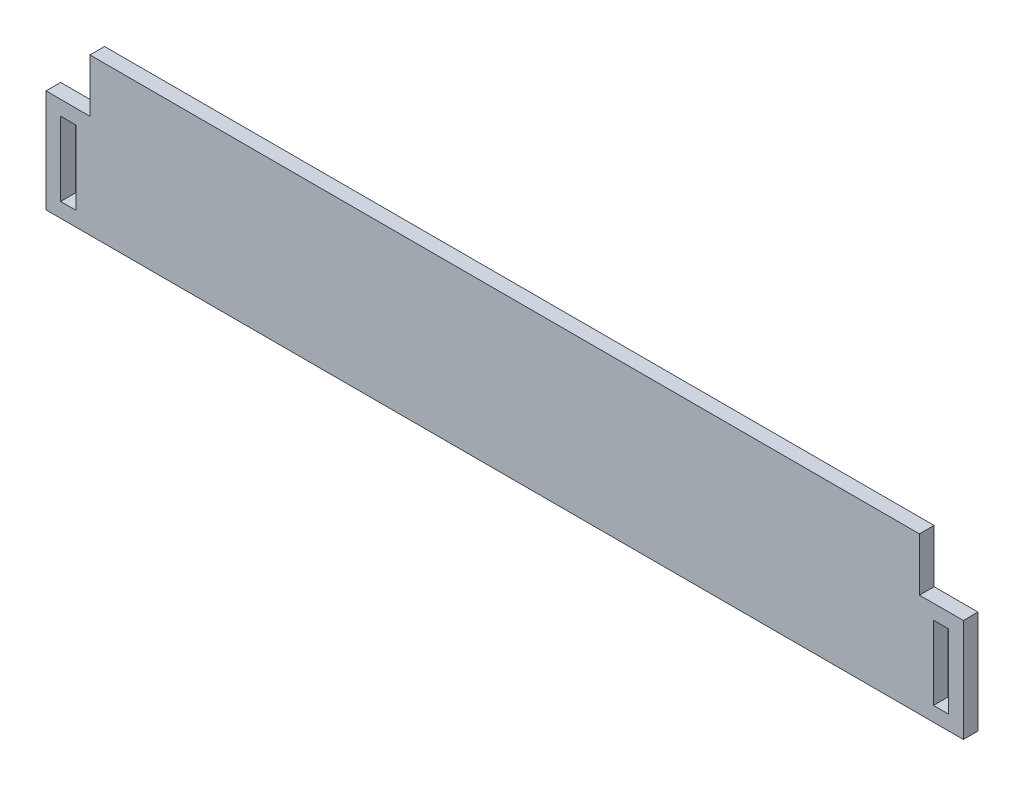
from build123d import *

# Parameters (mm, degrees)
CROQUIS1_W              = 3.123
CROQUIS1_H              = 15.13
SALIENTE_EXTRUIR1_DEPTH = 3


with BuildPart() as part:
    # Croquis1 → Saliente-Extruir1 (new body)
    with BuildSketch(Plane.XY):
        Polygon((-94, 0), (94, 0), (94, 21.123), (85, 21.123), (85, 32), (-85, 32), (-85, 21.123), (-94, 21.123), align=None)
        with Locations((-89.4385, 10.558)):
            Rectangle(CROQUIS1_W, CROQUIS1_H, mode=Mode.SUBTRACT)
        with Locations((89.4385, 10.558)):
            Rectangle(CROQUIS1_W, CROQUIS1_H, mode=Mode.SUBTRACT)
    extrude(amount=SALIENTE_EXTRUIR1_DEPTH)


solid = part.part
